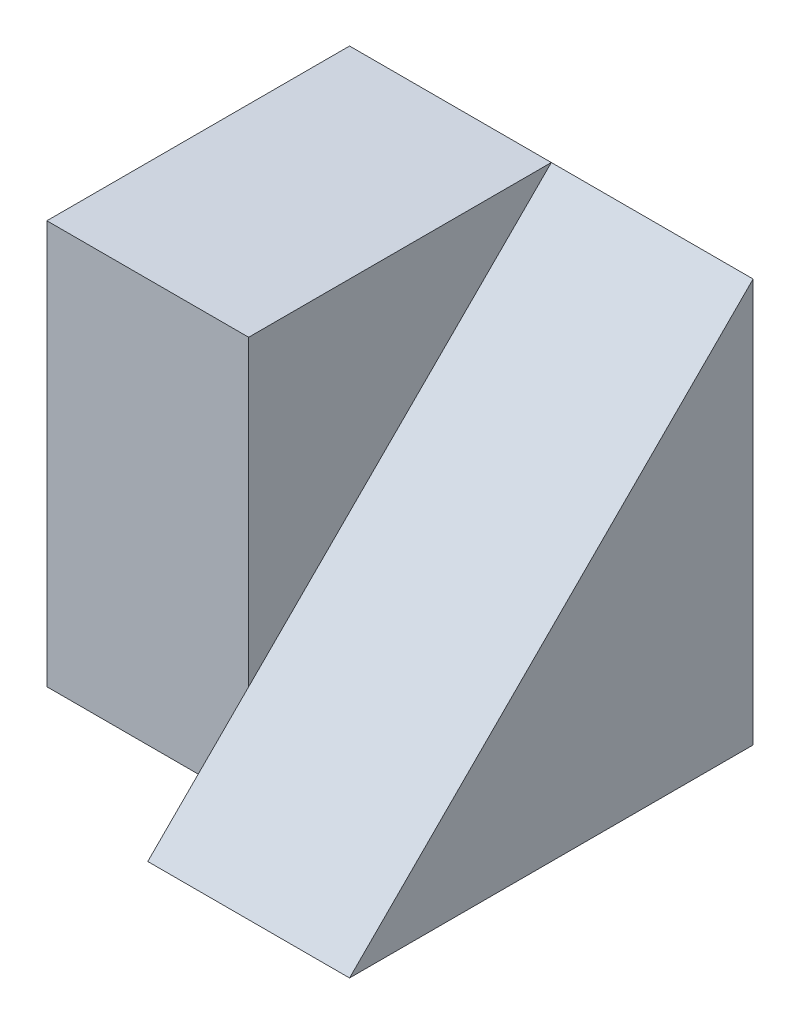
from build123d import *

# Parameters (mm, degrees)
SKETCH1_W           = 4
SKETCH1_H           = 4
BOSS_EXTRUDE1_DEPTH = 2
SKETCH2_W           = 3
SKETCH2_H           = 4
BOSS_EXTRUDE2_DEPTH = 2
CUT_EXTRUDE1_DEPTH  = 2


with BuildPart() as part:
    # Sketch1 → Boss-Extrude1 (new body)
    with BuildSketch(Plane(origin=(0, 0, 0), x_dir=(0, 0, -1), z_dir=(1, 0, 0))):
        with Locations((2, 2)):
            Rectangle(SKETCH1_W, SKETCH1_H)
    extrude(amount=BOSS_EXTRUDE1_DEPTH)

    # Sketch2 → Boss-Extrude2 (add)
    with BuildSketch(Plane.ZY):
        with Locations((-2.5, 2)):
            Rectangle(SKETCH2_W, SKETCH2_H)
    extrude(amount=BOSS_EXTRUDE2_DEPTH)

    # Sketch3 → Cut-Extrude1 (cut)
    with BuildSketch(Plane(origin=(2, 0, 0), x_dir=(0, 0, -1), z_dir=(1, 0, 0))):
        Polygon((0, 0), (4, 4), (0, 4), align=None)
    extrude(amount=-CUT_EXTRUDE1_DEPTH, mode=Mode.SUBTRACT)


solid = part.part
